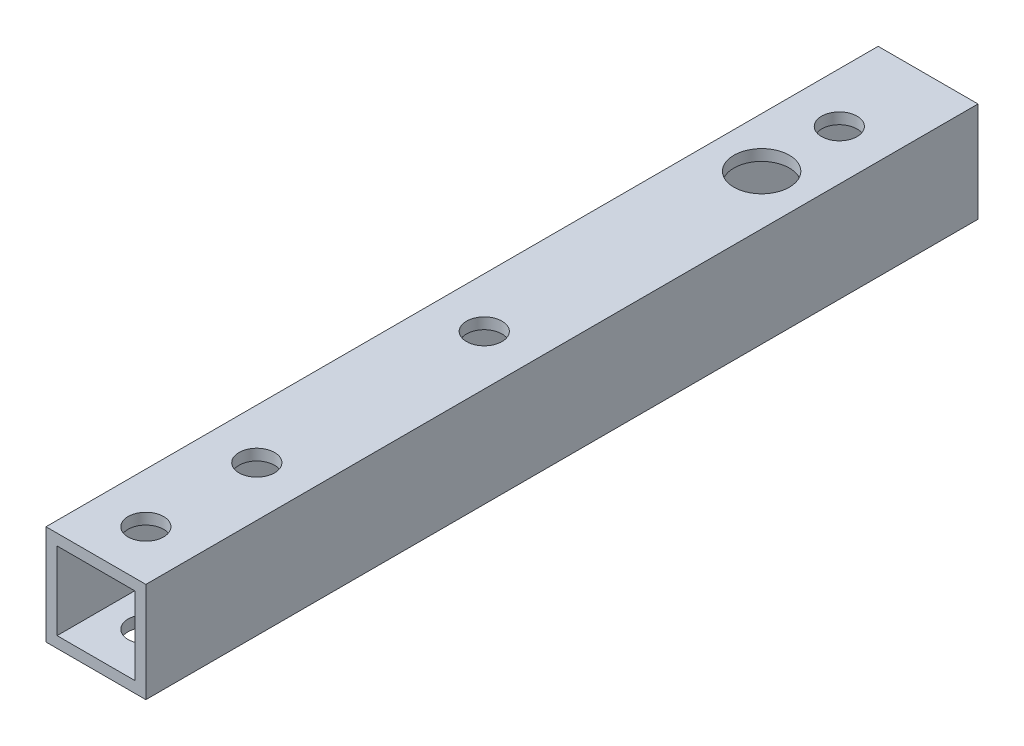
from build123d import *

# Parameters (mm, degrees)
SKETCH_1_W          = 9
SKETCH_1_H          = 9
SKETCH_1_W_2        = 7
SKETCH_1_H_2        = 7
EXTRUDE_1_DEPTH     = 70
CUT_EXTRUDE_1_DEPTH = 100
SKETCH_3_R          = 1.6
CUT_EXTRUDE_2_DEPTH = 100
SKETCH_4_R          = 1.6
CUT_EXTRUDE_3_DEPTH = 100
SKETCH_5_R          = 1.6
CUT_EXTRUDE_4_DEPTH = 10
SKETCH_6_W          = 9
SKETCH_6_H          = 9
SKETCH_6_W_2        = 7
SKETCH_6_H_2        = 7
EXTRUDE_2_DEPTH     = 5


with BuildPart() as part:
    # ｽｹｯﾁ1 → ﾎﾞｽ - 押し出し1 (new body)
    with BuildSketch(Plane.XY):
        Rectangle(SKETCH_1_W, SKETCH_1_H)
        Rectangle(SKETCH_1_W_2, SKETCH_1_H_2, mode=Mode.SUBTRACT)
    extrude(amount=EXTRUDE_1_DEPTH)

    # ｽｹｯﾁ2 → ｶｯﾄ - 押し出し1 (cut)
    with BuildSketch(Plane(origin=(0, 4.5, 0), x_dir=(1, 0, 0), z_dir=(0, 1, 0))):
        with BuildLine():
            ThreePointArc((2.5, -10), (1.767766953, -8.232233047), (0, -7.5))
            Line((0, -7.5), (0, -10))
            Line((0, -10), (0, -12.5))
            ThreePointArc((0, -12.5), (1.767766953, -11.767766953), (2.5, -10))
        make_face()
        with BuildLine():
            Line((0, -10), (0, -7.5))
            ThreePointArc((0, -7.5), (-2.5, -10), (0, -12.5))
            Line((0, -12.5), (0, -10))
        make_face()
    extrude(amount=-CUT_EXTRUDE_1_DEPTH, mode=Mode.SUBTRACT)

    # ｽｹｯﾁ3 → ｶｯﾄ - 押し出し2 (cut)
    with BuildSketch(Plane(origin=(0, 4.5, 0), x_dir=(1, 0, 0), z_dir=(0, 1, 0))):
        with Locations((0, -3)):
            Circle(SKETCH_3_R)
    extrude(amount=-CUT_EXTRUDE_2_DEPTH, mode=Mode.SUBTRACT)

    # ｽｹｯﾁ4 → ｶｯﾄ - 押し出し3 (cut)
    with BuildSketch(Plane(origin=(0, 4.5, 0), x_dir=(1, 0, 0), z_dir=(0, 1, 0))):
        with Locations((0, -65.5)):
            Circle(SKETCH_4_R)
        with Locations((0, -55.5)):
            Circle(SKETCH_4_R)
    extrude(amount=-CUT_EXTRUDE_3_DEPTH, mode=Mode.SUBTRACT)

    # ｽｹｯﾁ5 → ｶｯﾄ - 押し出し4 (cut, through all)
    with BuildSketch(Plane(origin=(0, 4.5, 0), x_dir=(1, 0, 0), z_dir=(0, 1, 0))):
        with Locations((0, -35)):
            Circle(SKETCH_5_R)
    extrude(amount=-CUT_EXTRUDE_4_DEPTH, mode=Mode.SUBTRACT)

    # ｽｹｯﾁ6 → ﾎﾞｽ - 押し出し2 (add)
    with BuildSketch(Plane(origin=(0, 0, 0), x_dir=(-1, 0, 0), z_dir=(0, 0, -1))):
        Rectangle(SKETCH_6_W, SKETCH_6_H)
        Rectangle(SKETCH_6_W_2, SKETCH_6_H_2, mode=Mode.SUBTRACT)
    extrude(amount=EXTRUDE_2_DEPTH)


solid = part.part
